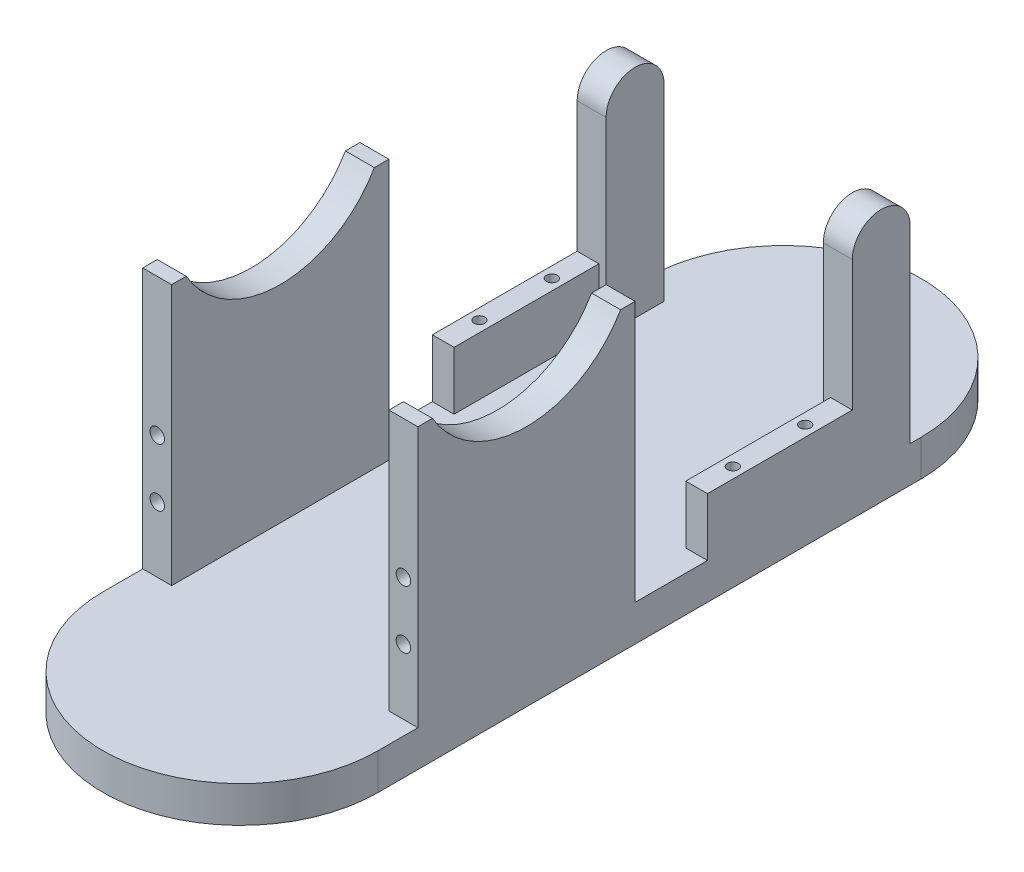
from build123d import *

# Parameters (mm, degrees)
EXTRUDE_1_DEPTH     = 10
SKETCH_3_W          = 8
SKETCH_3_H          = 60
EXTRUDE_2_DEPTH     = 72
SKETCH_4_W          = 6
SKETCH_4_H          = 40
EXTRUDE_3_DEPTH     = 16
SKETCH_5_R          = 30
CUT_EXTRUDE_1_DEPTH = 77
SKETCH_6_R          = 2
CUT_EXTRUDE_2_DEPTH = 10
SKETCH_7_R          = 1.5
CUT_EXTRUDE_3_DEPTH = 10
SKETCH_8_W          = 8
SKETCH_8_H          = 16
EXTRUDE_4_DEPTH     = 60
CUT_EXTRUDE_4_DEPTH = 77


with BuildPart() as part:
    # 草图1 → 凸台-拉伸1 (new body)
    with BuildSketch(Plane(origin=(0, 0, 0), x_dir=(1, 0, 0), z_dir=(0, 1, 0))):
        with BuildLine():
            Line((-38, -75), (-38, 75))
            ThreePointArc((-38, 75), (0, 113), (38, 75))
            Line((38, 75), (38, -75))
            ThreePointArc((38, -75), (0, -113), (-38, -75))
        make_face()
    extrude(amount=EXTRUDE_1_DEPTH)

    # 草图3 → 凸台-拉伸2 (add)
    with BuildSketch(Plane(origin=(0, 10, 0), x_dir=(1, 0, 0), z_dir=(0, 1, 0))):
        with Locations((-34, -34)):
            Rectangle(SKETCH_3_W, SKETCH_3_H)
        with Locations((34, -34)):
            Rectangle(SKETCH_3_W, SKETCH_3_H)
    extrude(amount=EXTRUDE_2_DEPTH)

    # 草图4 → 凸台-拉伸3 (add)
    with BuildSketch(Plane(origin=(0, 10, 0), x_dir=(1, 0, 0), z_dir=(0, 1, 0))):
        with Locations((-35, 36)):
            Rectangle(SKETCH_4_W, SKETCH_4_H)
        with Locations((35, 36)):
            Rectangle(SKETCH_4_W, SKETCH_4_H)
    extrude(amount=EXTRUDE_3_DEPTH)

    # 草图5 → 切除-拉伸1 (cut, through all)
    with BuildSketch(Plane(origin=(38, 0, 0), x_dir=(0, 0, -1), z_dir=(1, 0, 0))):
        with Locations((-34, 97)):
            Circle(SKETCH_5_R)
    extrude(amount=-CUT_EXTRUDE_1_DEPTH, mode=Mode.SUBTRACT)

    # 草图6 → 切除-拉伸2 (cut)
    with BuildSketch(Plane.XY.offset(64)):
        with Locations((-34, 44)):
            Circle(SKETCH_6_R)
        with Locations((-34, 28)):
            Circle(SKETCH_6_R)
        with Locations((34, 44)):
            Circle(SKETCH_6_R)
        with Locations((34, 28)):
            Circle(SKETCH_6_R)
    extrude(amount=-CUT_EXTRUDE_2_DEPTH, mode=Mode.SUBTRACT)

    # 草图7 → 切除-拉伸3 (cut)
    with BuildSketch(Plane(origin=(0, 26, 0), x_dir=(1, 0, 0), z_dir=(0, 1, 0))):
        with Locations((-35, 26)):
            Circle(SKETCH_7_R)
        with Locations((-35, 46)):
            Circle(SKETCH_7_R)
        with Locations((35, 26)):
            Circle(SKETCH_7_R)
        with Locations((35, 46)):
            Circle(SKETCH_7_R)
    extrude(amount=-CUT_EXTRUDE_3_DEPTH, mode=Mode.SUBTRACT)

    # 草图8 → 凸台-拉伸4 (add)
    with BuildSketch(Plane(origin=(0, 10, 0), x_dir=(1, 0, 0), z_dir=(0, 1, 0))):
        with Locations((-34, 64)):
            Rectangle(SKETCH_8_W, SKETCH_8_H)
        with Locations((34, 64)):
            Rectangle(SKETCH_8_W, SKETCH_8_H)
    extrude(amount=EXTRUDE_4_DEPTH)

    # 草图9 → 切除-拉伸4 (cut, through all)
    with BuildSketch(Plane(origin=(38, 0, 0), x_dir=(0, 0, -1), z_dir=(1, 0, 0))):
        with BuildLine():
            Line((56, 62), (56, 75))
            Line((56, 75), (72, 75))
            Line((72, 75), (72, 62))
            ThreePointArc((72, 62), (64, 70), (56, 62))
        make_face()
    extrude(amount=-CUT_EXTRUDE_4_DEPTH, mode=Mode.SUBTRACT)


solid = part.part
